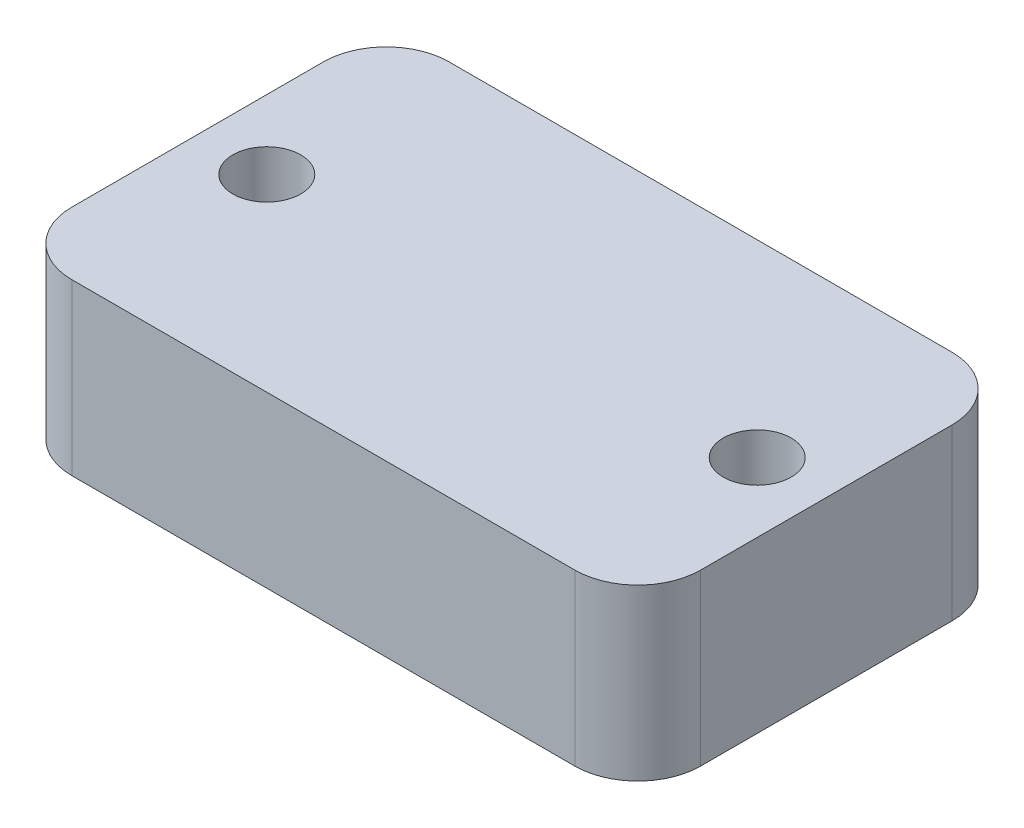
from build123d import *

# Parameters (mm, degrees)
SKETCH1_R           = 2.7
BOSS_EXTRUDE1_DEPTH = 13.5


with BuildPart() as part:
    # Sketch1 → Boss-Extrude1 (new body)
    with BuildSketch(Plane(origin=(0, 0, 0), x_dir=(1, 0, 0), z_dir=(0, 1, 0))):
        with BuildLine():
            Line((20, -15), (-20, -15))
            ThreePointArc((-20, -15), (-23.535533906, -13.535533906), (-25, -10))
            Line((-25, -10), (-25, 10))
            ThreePointArc((-25, 10), (-23.535533906, 13.535533906), (-20, 15))
            Line((-20, 15), (20, 15))
            ThreePointArc((20, 15), (23.535533906, 13.535533906), (25, 10))
            Line((25, 10), (25, -10))
            ThreePointArc((25, -10), (23.535533906, -13.535533906), (20, -15))
        make_face()
        with Locations((-19.5, 0)):
            Circle(SKETCH1_R, mode=Mode.SUBTRACT)
        with Locations((19.5, 0)):
            Circle(SKETCH1_R, mode=Mode.SUBTRACT)
    extrude(amount=BOSS_EXTRUDE1_DEPTH)


solid = part.part
